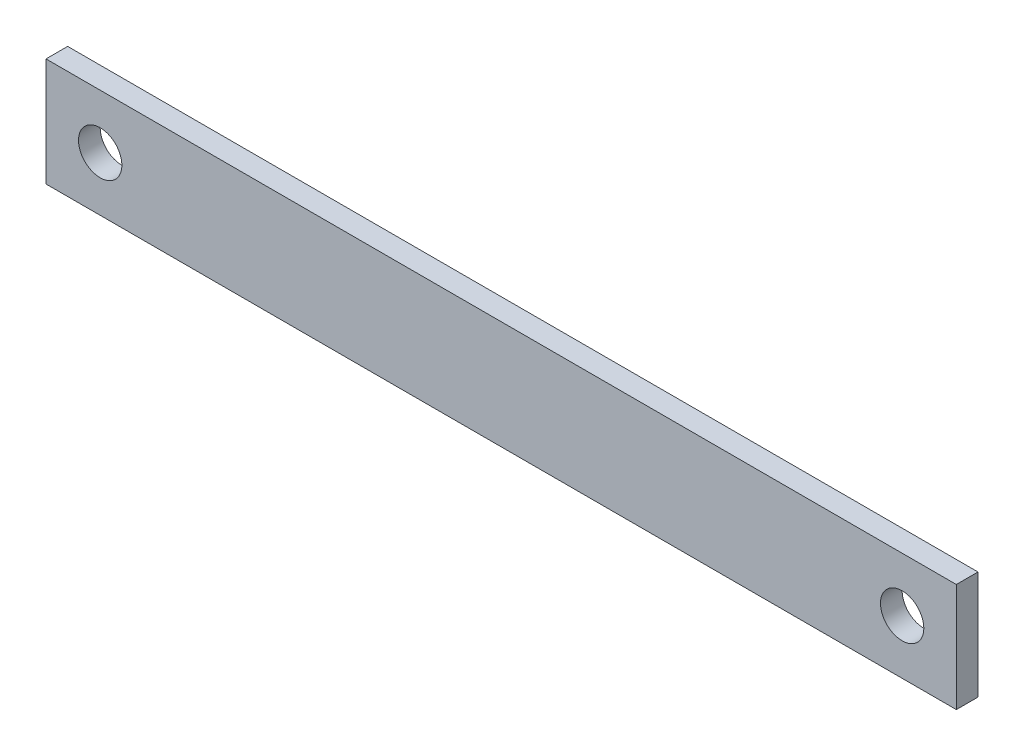
from build123d import *

# Parameters (mm, degrees)
SKETCH1_W           = 84
SKETCH1_H           = 10
BOSS_EXTRUDE1_DEPTH = 2
SKETCH2_R           = 2
CUT_EXTRUDE1_DEPTH  = 10


with BuildPart() as part:
    # Sketch1 → Boss-Extrude1 (new body)
    with BuildSketch(Plane.XY):
        with Locations((-21.859072777, 0.831421638)):
            Rectangle(SKETCH1_W, SKETCH1_H)
    extrude(amount=BOSS_EXTRUDE1_DEPTH)

    # Sketch2 → Cut-Extrude1 (cut)
    with BuildSketch(Plane.XY.offset(2)):
        with Locations((-58.859072777, 0.831421638)):
            Circle(SKETCH2_R)
        with Locations((15.140927223, 0.831421638)):
            Circle(SKETCH2_R)
    extrude(amount=-CUT_EXTRUDE1_DEPTH, mode=Mode.SUBTRACT)


solid = part.part
